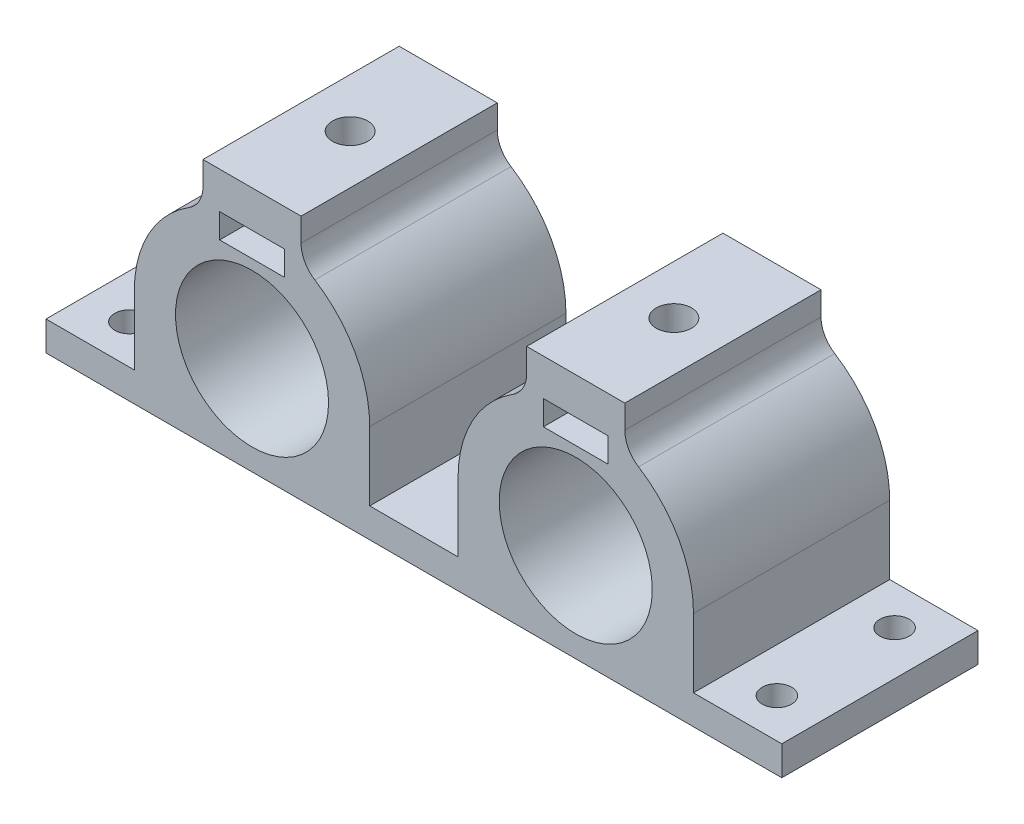
from build123d import *

# Parameters (mm, degrees)
ESBO_O1_W                = 6.6
ESBO_O1_H                = 2.5
RESSALTO_EXTRUS_O1_DEPTH = 20
ESBO_O2_R                = 1.5
CORTE_EXTRUS_O1_DEPTH    = 26
ESBO_O4_R                = 1.8
CORTE_EXTRUS_O2_DEPTH    = 16


with BuildPart() as part:
    # Esboço1 → Ressalto-extrusão1 (new body)
    with BuildSketch(Plane.XY):
        with BuildLine():
            Line((-12, 0), (-12, -7))
            Line((-12, -7), (-21, -7))
            Line((-21, -7), (-21, -10))
            Line((-21, -10), (54, -10))
            Line((54, -10), (54, -7))
            Line((54, -7), (45, -7))
            Line((45, -7), (45, 0))
            ThreePointArc((45, 0), (43.507140429, 5.796550698), (39.4, 10.150862032))
            ThreePointArc((39.4, 10.150862032), (38.373214893, 11.239439866), (38, 12.68857754))
            Line((38, 12.68857754), (38, 15.080826084))
            Line((38, 15.080826084), (28, 15.080826084))
            Line((28, 15.080826084), (28, 12.68857754))
            ThreePointArc((28, 12.68857754), (27.626785107, 11.239439866), (26.6, 10.150862032))
            ThreePointArc((26.6, 10.150862032), (22.492859571, 5.796550698), (21, 0))
            Line((21, 0), (21, -7))
            Line((21, -7), (12, -7))
            Line((12, -7), (12, 0))
            ThreePointArc((12, 0), (10.507140429, 5.796550698), (6.4, 10.150862032))
            ThreePointArc((6.4, 10.150862032), (5.373214893, 11.239439866), (5, 12.68857754))
            Line((5, 12.68857754), (5, 15.080826084))
            Line((5, 15.080826084), (-5, 15.080826084))
            Line((-5, 15.080826084), (-5, 12.68857754))
            ThreePointArc((-5, 12.68857754), (-5.373214893, 11.239439866), (-6.4, 10.150862032))
            ThreePointArc((-6.4, 10.150862032), (-10.507140429, 5.796550698), (-12, 0))
        make_face()
        with Locations((0, 10.080826084)):
            Rectangle(ESBO_O1_W, ESBO_O1_H, mode=Mode.SUBTRACT)
        with Locations((33, 10.080826084)):
            Rectangle(ESBO_O1_W, ESBO_O1_H, mode=Mode.SUBTRACT)
        with BuildLine():
            ThreePointArc((7.8, 0), (0, 7.8), (-7.8, 0))
            ThreePointArc((-7.8, 0), (0, -7.8), (7.8, 0))
        make_face(mode=Mode.SUBTRACT)
        with BuildLine():
            ThreePointArc((40.8, 0), (33, -7.8), (25.2, 0))
            ThreePointArc((25.2, 0), (33, 7.8), (40.8, 0))
        make_face(mode=Mode.SUBTRACT)
    extrude(amount=RESSALTO_EXTRUS_O1_DEPTH)

    # Esboço2 → Corte-extrusão1 (cut)
    with BuildSketch(Plane(origin=(0, -7, 0), x_dir=(1, 0, 0), z_dir=(0, 1, 0))):
        with Locations((-16.5, -4)):
            Circle(ESBO_O2_R)
        with Locations((-16.5, -16)):
            Circle(ESBO_O2_R)
        with Locations((49.5, -16)):
            Circle(ESBO_O2_R)
        with Locations((49.5, -4)):
            Circle(ESBO_O2_R)
        with Locations((16.5, -10)):
            Circle(ESBO_O2_R)
    extrude(amount=-CORTE_EXTRUS_O1_DEPTH, mode=Mode.SUBTRACT)

    # Esboço4 → Corte-extrusão2 (cut)
    with BuildSketch(Plane(origin=(0, 15.080826084, 0), x_dir=(1, 0, 0), z_dir=(0, 1, 0))):
        with Locations((0, -10)):
            Circle(ESBO_O4_R)
        with Locations((33, -10)):
            Circle(ESBO_O4_R)
    extrude(amount=-CORTE_EXTRUS_O2_DEPTH, mode=Mode.SUBTRACT)


solid = part.part
